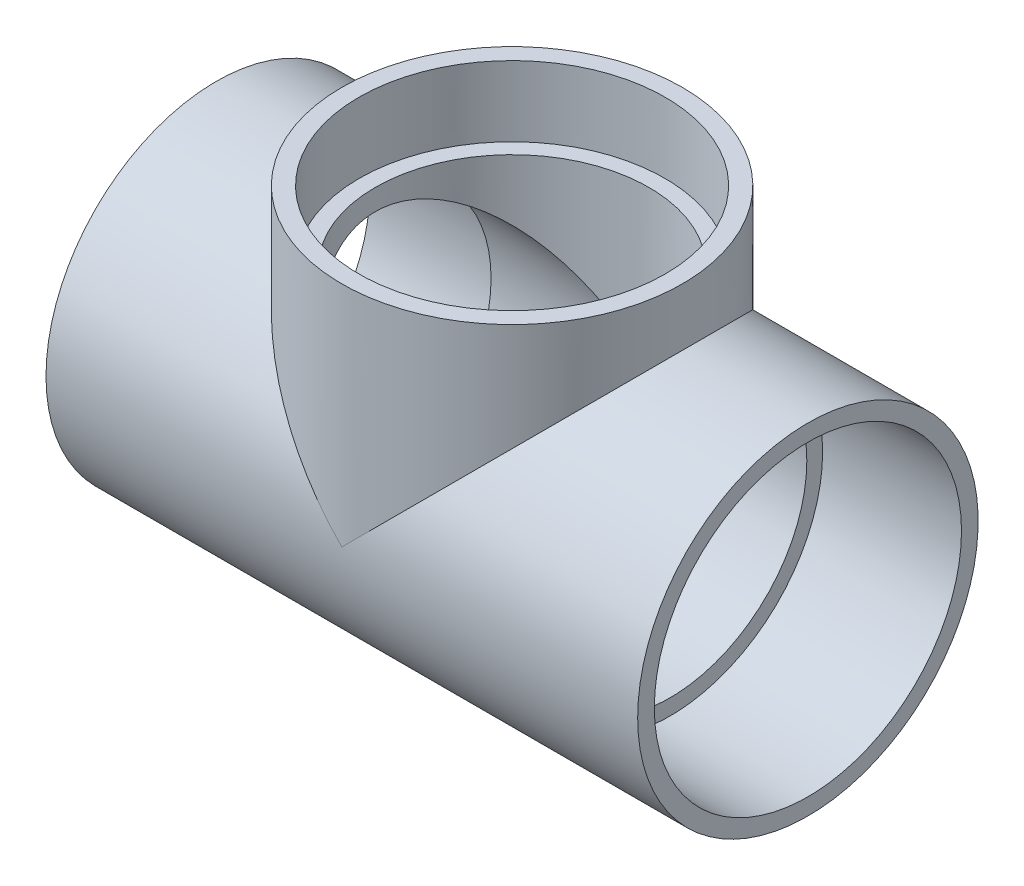
from build123d import *

# Parameters (mm, degrees)
SKETCH4_R           = 63.6016
BOSS_EXTRUDE1_DEPTH = 117.9576
SKETCH5_R           = 63.6016
BOSS_EXTRUDE2_DEPTH = 58.9788
SKETCH8_R           = 92.190098926
SKETCH8_R_2         = 25.050168183
CUT_EXTRUDE1_DEPTH  = 25.4


with BuildPart() as part:
    # Sketch1 → Revolve1 (revolve)
    with BuildSketch(Plane.XY):
        Polygon((-110.5154, -63.6016), (-58.9788, -63.6016), (-58.9788, -57.0357), (-110.5154, -57.3786), align=None)
        Polygon((110.5154, -57.3786), (58.9788, -57.0357), (58.9788, -63.6016), (110.5154, -63.6016), align=None)
    revolve(axis=Axis((-110.5154, 0, 0), (1, 0, 0)))



with BuildPart() as body_2:
    # Sketch2 → Revolve2 (revolve)
    with BuildSketch(Plane.XY):
        Polygon((57.3786, 110.5154), (57.0357, 58.9788), (63.6016, 58.9788), (63.6016, 110.5154), align=None)
    revolve(axis=Axis((0, 0, 0), (0, 1, 0)))


with BuildPart() as part_1:
    add(part.part)

    add(body_2.part)  # Boss-Extrude1 merges body 2
    # Sketch4 → Boss-Extrude1 (add)
    with BuildSketch(Plane(origin=(-58.9788, 0, 0), x_dir=(0, 0, -1), z_dir=(1, 0, 0))):
        Circle(SKETCH4_R)
    extrude(amount=BOSS_EXTRUDE1_DEPTH)

    # Sketch5 → Boss-Extrude2 (add)
    with BuildSketch(Plane.XZ.offset(-58.9788)):
        Circle(SKETCH5_R)
    extrude(amount=BOSS_EXTRUDE2_DEPTH)

    # Sketch6 → Cut-Revolve1 (revolve, cut)
    with BuildSketch(Plane.XY):
        Polygon((-110.5154, -57.3786), (-58.9788, -57.0357), (-58.9788, -51.1302), (58.9788, -51.1302), (58.9788, -57.0357), (110.5154, -57.3786), (110.5154, 0), (-110.5154, 0), align=None)
    revolve(axis=Axis((110.5154, 0, 0), (-1, 0, 0)), mode=Mode.SUBTRACT)

    # Sketch7 → Cut-Revolve2 (revolve, cut)
    with BuildSketch(Plane.XY):
        Polygon((57.3786, 110.5154), (57.0357, 58.9788), (51.1302, 58.9788), (51.1302, 0), (0, 0), (0, 110.5154), align=None)
    revolve(axis=Axis((0, 0, 0), (0, 1, 0)), mode=Mode.SUBTRACT)

    # Sketch8 → Cut-Extrude1 (cut)
    with BuildSketch(Plane(origin=(0, 110.5154, 0), x_dir=(1, 0, 0), z_dir=(0, 1, 0))):
        Circle(SKETCH8_R)
        Circle(SKETCH8_R_2, mode=Mode.SUBTRACT)
    extrude(amount=-CUT_EXTRUDE1_DEPTH, mode=Mode.SUBTRACT)


solid = part_1.part
